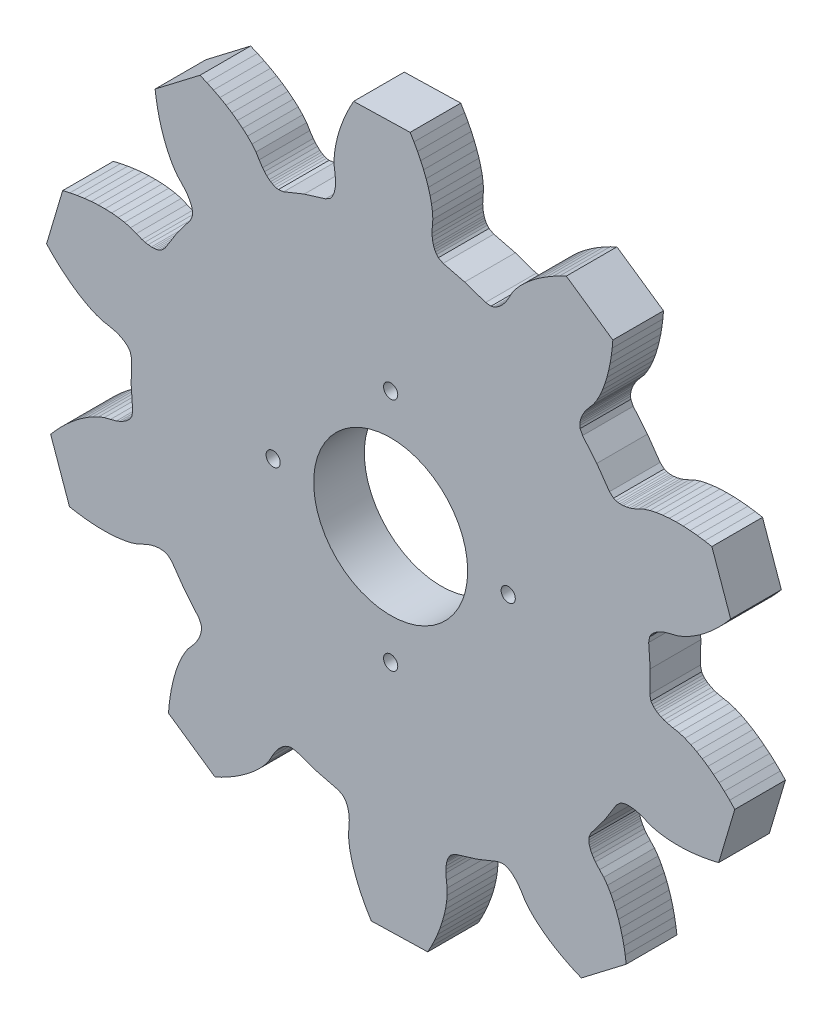
from build123d import *

# Parameters (mm, degrees)
SKETCH1_R           = 4.826
BOSS_EXTRUDE1_DEPTH = 3.175
SKETCH2_R           = 0.4445
CUT_EXTRUDE1_DEPTH  = 4.175
CIRPATTERN1_COUNT   = 4


with BuildPart() as part:
    # Sketch1 → Boss-Extrude1 (new body)
    with BuildSketch(Plane.XY):
        Polygon((5.804408, 23.022306), (5.731256, 23.354538), (5.645912, 23.48865), (5.558282, 23.588218), (5.469382, 23.669244), (5.379466, 23.73757), (5.288788, 23.797006), (5.105908, 23.894796), (4.920742, 23.972012), (4.733798, 24.033226), (4.3561, 24.118316), (3.976624, 24.186642), (3.604006, 24.311356), (3.236214, 24.472138), (2.872994, 24.661622), (2.514346, 24.875998), (2.160524, 25.113742), (1.812036, 25.373076), (1.469136, 25.65273), (1.132332, 25.95245), (0.801624, 26.270712), (0.477774, 26.60777), (1.487424, 30.00375), (1.942846, 30.108906), (2.393696, 30.195012), (2.83972, 30.26156), (3.279648, 30.30855), (3.713226, 30.335474), (4.139438, 30.341062), (4.557014, 30.32506), (4.964684, 30.285182), (5.360416, 30.218888), (5.740908, 30.119574), (6.096, 29.96946), (6.458966, 29.834332), (6.648704, 29.783532), (6.846062, 29.746956), (7.052818, 29.728922), (7.161022, 29.729176), (7.273798, 29.737304), (7.392416, 29.756608), (7.520432, 29.792168), (7.664958, 29.857954), (7.907782, 30.096206), (8.645652, 31.271718), (9.481058, 32.380428), (9.617202, 32.692086), (9.627108, 32.850582), (9.614916, 32.982662), (9.590532, 33.100518), (9.55802, 33.208722), (9.519412, 33.310068), (9.428988, 33.496758), (9.324594, 33.668208), (9.209278, 33.827466), (8.953754, 34.118296), (8.6868, 34.39668), (8.458708, 34.716466), (8.255508, 35.062922), (8.073136, 35.429444), (7.909052, 35.814), (7.762748, 36.21405), (7.633208, 36.628578), (7.520178, 37.056568), (7.423658, 37.497004), (7.343394, 37.94887), (7.279386, 38.411912), (10.092436, 40.565832), (10.522458, 40.383206), (10.938002, 40.18788), (11.337798, 39.9796), (11.721592, 39.758874), (12.088114, 39.525702), (12.436094, 39.280084), (12.764516, 39.021512), (13.07084, 38.749732), (13.352018, 38.46322), (13.601446, 38.15969), (13.800582, 37.829236), (14.014704, 37.506656), (14.138402, 37.354002), (14.276578, 37.20846), (14.433296, 37.072316), (14.520926, 37.008816), (14.616938, 36.949126), (14.72438, 36.895024), (14.848586, 36.848542), (15.004288, 36.816792), (15.340838, 36.86683), (16.628872, 37.384228), (17.956276, 37.789866), (18.249646, 37.962078), (18.350738, 38.08476), (18.418556, 38.198806), (18.468086, 38.30828), (18.505424, 38.41496), (18.533618, 38.519608), (18.570194, 38.723824), (18.58645, 38.923722), (18.586958, 39.120318), (18.551144, 39.50589), (18.49882, 39.887906), (18.502376, 40.281098), (18.541492, 40.680386), (18.60931, 41.0845), (18.702782, 41.491662), (18.819368, 41.901618), (18.958306, 42.313098), (19.118326, 42.725848), (19.299174, 43.138852), (19.499834, 43.551602), (19.720306, 43.963844), (23.262082, 44.052744), (23.502874, 43.652186), (23.724108, 43.250104), (23.925276, 42.846498), (24.10587, 42.442638), (24.265128, 42.038524), (24.402542, 41.635172), (24.51608, 41.232836), (24.604218, 40.832786), (24.6634, 40.436038), (24.686768, 40.043608), (24.653494, 39.659306), (24.637238, 39.272464), (24.647652, 39.076122), (24.673814, 38.87724), (24.72055, 38.675056), (24.754078, 38.572186), (24.79675, 38.467538), (24.851614, 38.360604), (24.92502, 38.24986), (25.032208, 38.132512), (25.33396, 37.975286), (26.68016, 37.636958), (27.992578, 37.184838), (28.330906, 37.151818), (28.48483, 37.191442), (28.60675, 37.24402), (28.711144, 37.303456), (28.804108, 37.367718), (28.888436, 37.43579), (29.038296, 37.579554), (29.168852, 37.7317), (29.284676, 37.89045), (29.482288, 38.223444), (29.66466, 38.563296), (29.89834, 38.879272), (30.16504, 39.1795), (30.457394, 39.466266), (30.772354, 39.741094), (31.107634, 40.003984), (31.46171, 40.25519), (31.83382, 40.494966), (32.222948, 40.722804), (32.627824, 40.938958), (33.048448, 41.142666), (35.966146, 39.133018), (35.925506, 38.667436), (35.868102, 38.212014), (35.79368, 37.76726), (35.70224, 37.33419), (35.593782, 36.913566), (35.467544, 36.506658), (35.323272, 36.114482), (35.159442, 35.73907), (34.974022, 35.383216), (34.762186, 35.052), (34.509456, 34.760662), (34.268918, 34.457386), (34.161984, 34.29254), (34.066226, 34.116264), (33.9852, 33.925002), (33.951672, 33.821878), (33.924748, 33.71215), (33.90646, 33.593532), (33.900618, 33.460944), (33.918652, 33.302956), (34.070036, 32.99841), (34.960306, 31.933388), (35.756342, 30.79623), (36.010596, 30.570424), (36.158424, 30.512004), (36.287964, 30.482794), (36.407598, 30.469586), (36.520374, 30.467046), (36.628578, 30.47238), (36.834318, 30.500828), (37.02939, 30.54731), (37.216588, 30.607508), (37.572188, 30.76067), (37.919406, 30.928564), (38.294056, 31.046674), (38.686232, 31.13278), (39.091362, 31.192978), (39.507668, 31.230316), (39.933372, 31.24581), (40.367712, 31.240984), (40.809672, 31.216092), (41.258236, 31.171896), (41.71315, 31.10865), (42.173144, 31.026354), (43.352212, 27.685492), (43.045634, 27.332686), (42.731436, 26.998168), (42.409872, 26.681938), (42.08145, 26.385266), (41.746424, 26.108914), (41.405302, 25.853644), (41.05783, 25.621488), (40.704516, 25.41397), (40.34536, 25.2349), (39.979346, 25.091644), (39.60368, 25.004268), (39.230808, 24.900382), (39.04742, 24.830024), (38.866318, 24.74341), (38.688264, 24.636476), (38.600888, 24.572722), (38.514528, 24.499824), (38.429692, 24.41448), (38.347142, 24.310594), (38.26891, 24.172418), (38.212522, 23.836884), (38.306502, 22.452076), (38.282118, 21.06422), (38.35527, 20.731988), (38.440614, 20.597876), (38.528244, 20.498308), (38.617144, 20.417282), (38.70706, 20.348956), (38.797738, 20.28952), (38.980618, 20.19173), (39.165784, 20.114514), (39.352728, 20.0533), (39.730426, 19.96821), (40.109902, 19.899884), (40.48252, 19.77517), (40.850312, 19.614388), (41.213532, 19.424904), (41.57218, 19.210528), (41.925748, 18.972784), (42.27449, 18.71345), (42.61739, 18.433796), (42.954194, 18.134076), (43.284902, 17.815814), (43.608752, 17.478756), (42.598848, 14.082776), (42.14368, 13.97762), (41.69283, 13.891514), (41.246806, 13.824966), (40.806878, 13.777976), (40.3733, 13.751052), (39.947088, 13.745464), (39.529512, 13.761466), (39.121842, 13.801344), (38.72611, 13.867638), (38.345618, 13.966952), (37.990526, 14.117066), (37.62756, 14.252194), (37.437822, 14.302994), (37.240464, 14.33957), (37.033708, 14.357604), (36.925504, 14.35735), (36.812728, 14.349222), (36.69411, 14.329918), (36.566094, 14.294358), (36.421568, 14.228572), (36.178744, 13.99032), (35.440874, 12.814808), (34.605468, 11.706098), (34.469324, 11.39444), (34.459418, 11.235944), (34.47161, 11.103864), (34.495994, 10.986008), (34.528506, 10.877804), (34.567114, 10.776458), (34.657538, 10.589768), (34.761932, 10.418318), (34.877248, 10.25906), (35.132772, 9.96823), (35.399726, 9.689846), (35.627818, 9.37006), (35.831018, 9.023604), (36.01339, 8.657082), (36.177474, 8.272526), (36.323778, 7.872476), (36.453318, 7.457948), (36.566348, 7.029958), (36.662868, 6.589522), (36.743132, 6.137656), (36.80714, 5.674614), (33.99409, 3.520694), (33.564068, 3.70332), (33.148524, 3.898646), (32.748728, 4.106926), (32.364934, 4.327398), (31.998412, 4.560824), (31.650432, 4.806442), (31.32201, 5.065014), (31.015686, 5.336794), (30.734508, 5.623306), (30.48508, 5.926836), (30.285944, 6.25729), (30.071822, 6.57987), (29.948124, 6.732524), (29.809948, 6.878066), (29.65323, 7.01421), (29.5656, 7.07771), (29.469588, 7.1374), (29.362146, 7.191502), (29.23794, 7.237984), (29.082238, 7.269734), (28.745688, 7.219696), (27.457654, 6.702298), (26.13025, 6.29666), (25.83688, 6.124448), (25.735788, 6.001766), (25.66797, 5.88772), (25.61844, 5.778246), (25.581102, 5.671566), (25.552908, 5.566918), (25.516332, 5.362702), (25.500076, 5.162804), (25.499568, 4.966208), (25.535382, 4.580636), (25.587706, 4.19862), (25.58415, 3.805428), (25.545034, 3.40614), (25.477216, 3.002026), (25.383744, 2.594864), (25.267158, 2.184908), (25.12822, 1.773428), (24.9682, 1.360678), (24.787352, 0.947674), (24.586692, 0.534924), (24.36622, 0.122682), (20.824444, 0.033782), (20.583652, 0.43434), (20.362418, 0.836422), (20.16125, 1.240028), (19.980656, 1.643888), (19.821398, 2.048002), (19.683984, 2.451354), (19.570446, 2.85369), (19.482308, 3.25374), (19.423126, 3.650488), (19.399758, 4.042918), (19.433032, 4.42722), (19.449288, 4.814062), (19.438874, 5.010404), (19.412712, 5.209032), (19.365976, 5.41147), (19.332448, 5.51434), (19.289776, 5.618988), (19.234912, 5.725922), (19.161506, 5.836666), (19.054318, 5.954014), (18.752566, 6.11124), (17.406366, 6.449568), (16.093948, 6.901688), (15.75562, 6.934708), (15.601696, 6.895084), (15.479776, 6.842506), (15.375382, 6.78307), (15.282418, 6.718808), (15.19809, 6.650736), (15.04823, 6.506972), (14.917674, 6.354826), (14.80185, 6.196076), (14.604238, 5.863082), (14.421866, 5.52323), (14.188186, 5.207254), (13.921486, 4.907026), (13.629132, 4.62026), (13.314172, 4.345432), (12.978892, 4.082542), (12.624816, 3.831336), (12.252706, 3.59156), (11.863578, 3.363722), (11.458702, 3.147568), (11.038078, 2.94386), (8.12038, 4.953508), (8.16102, 5.41909), (8.218424, 5.874512), (8.292846, 6.319266), (8.384286, 6.752336), (8.492744, 7.17296), (8.618982, 7.579868), (8.763254, 7.972044), (8.927084, 8.347456), (9.112504, 8.70331), (9.32434, 9.034526), (9.57707, 9.325864), (9.817608, 9.62914), (9.924542, 9.793986), (10.0203, 9.970262), (10.101326, 10.161524), (10.134854, 10.264648), (10.161778, 10.374376), (10.180066, 10.492994), (10.185908, 10.625582), (10.167874, 10.78357), (10.01649, 11.088116), (9.12622, 12.153138), (8.330184, 13.290296), (8.07593, 13.516102), (7.928102, 13.574522), (7.798562, 13.603478), (7.678928, 13.61694), (7.566152, 13.61948), (7.457948, 13.614146), (7.252208, 13.585698), (7.057136, 13.539216), (6.869938, 13.479018), (6.514338, 13.325856), (6.16712, 13.157962), (5.79247, 13.039852), (5.400294, 12.953746), (4.995164, 12.893548), (4.578858, 12.85621), (4.153154, 12.840716), (3.718814, 12.845542), (3.276854, 12.870434), (2.82829, 12.91463), (2.373376, 12.977876), (1.913382, 13.060172), (0.734314, 16.401034), (1.040892, 16.75384), (1.35509, 17.088358), (1.676654, 17.404588), (2.005076, 17.70126), (2.340102, 17.977612), (2.681224, 18.232882), (3.028696, 18.465038), (3.38201, 18.672556), (3.741166, 18.851626), (4.10718, 18.994882), (4.482846, 19.082258), (4.855718, 19.186144), (5.039106, 19.256502), (5.220208, 19.342862), (5.398262, 19.45005), (5.485638, 19.513804), (5.571998, 19.586702), (5.656834, 19.672046), (5.739384, 19.775932), (5.817616, 19.914108), (5.874004, 20.249642), (5.780024, 21.63445), align=None)
        with Locations((22.043136, 22.043136)):
            Circle(SKETCH1_R, mode=Mode.SUBTRACT)
    extrude(amount=BOSS_EXTRUDE1_DEPTH)

    # Sketch2 → Cut-Extrude1 (cut, through all)
    with BuildSketch(Plane.XY.offset(3.175)):
        with Locations((14.677136, 22.043136)):
            Circle(SKETCH2_R)
    cut_extrude1 = extrude(amount=-CUT_EXTRUDE1_DEPTH, mode=Mode.SUBTRACT)

    # CirPattern1: Cut-Extrude1 ×4 about axis
    cirpattern1_axis = Axis((22.043136, 22.043136, 0), (0, 0, 1))
    for i in range(1, CIRPATTERN1_COUNT):
        add(cut_extrude1.rotate(cirpattern1_axis, i * 360 / CIRPATTERN1_COUNT), mode=Mode.SUBTRACT)


solid = part.part
